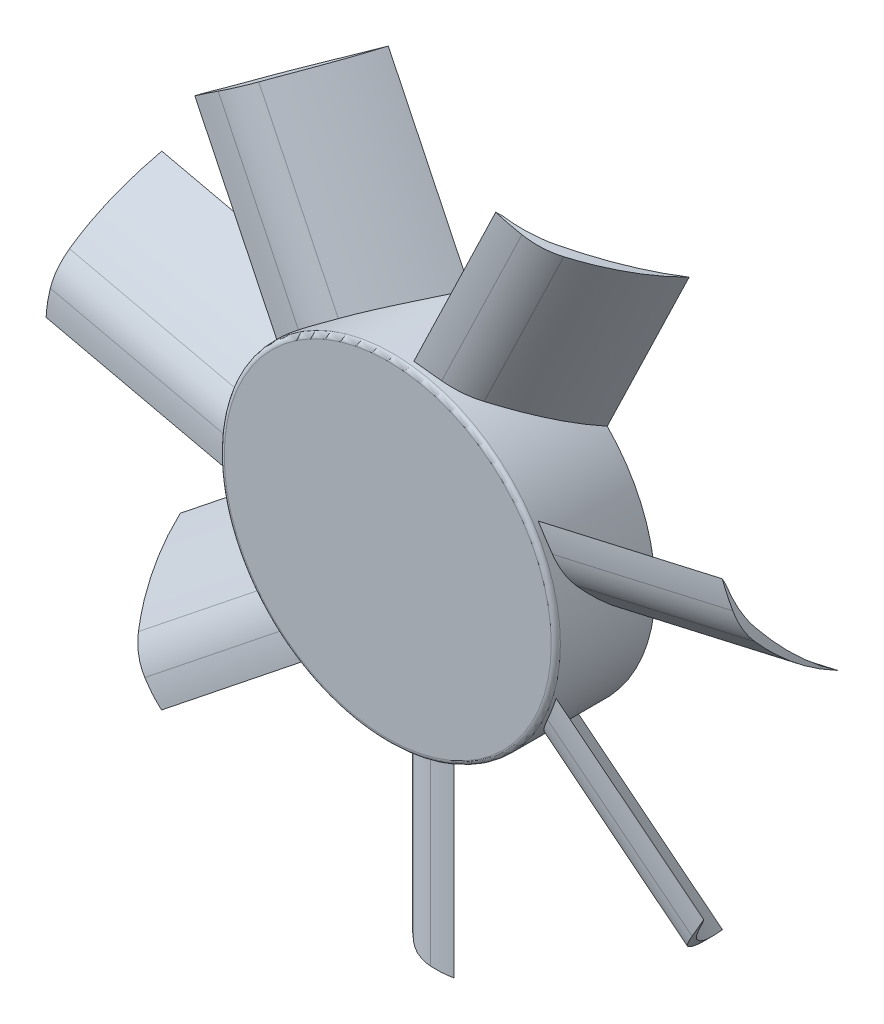
from build123d import *

# Parameters (mm, degrees)
SKETCH_1_R               = 11
EXTRUDE_1_DEPTH          = 6.5
SKETCH_2_R               = 9.75
CUT_EXTRUDE_1_DEPTH      = 5.5
SKETCH_3_R               = 0.7
EXTRUDE_2_DEPTH          = 7.5
CHAMFER_1_SIZE           = 0.6
EXTRUDE_START            = -10
EXTRUDE_3_DEPTH          = 23
PATTERN_CIRCULAR_1_COUNT = 7
FILLET_1_R               = 0.3
SKETCH_5_OUTSIDE_W       = 86.532
SKETCH_5_OUTSIDE_H       = 84.877
SKETCH_5_OUTSIDE_R       = 23
CUT_EXTRUDE_2_DEPTH      = 23


with BuildPart() as part:
    # Эскиз1 → Бобышка-Вытянуть1 (new body)
    with BuildSketch(Plane.XY):
        Circle(SKETCH_1_R)
    extrude(amount=EXTRUDE_1_DEPTH)

    # Эскиз2 → Вырез-Вытянуть1 (cut)
    with BuildSketch(Plane(origin=(0, 0, 0), x_dir=(-1, 0, 0), z_dir=(0, 0, -1))):
        Circle(SKETCH_2_R)
    extrude(amount=-CUT_EXTRUDE_1_DEPTH, mode=Mode.SUBTRACT)

    # Эскиз3 → Бобышка-Вытянуть2 (add)
    with BuildSketch(Plane(origin=(0, 0, 5.5), x_dir=(-1, 0, 0), z_dir=(0, 0, -1))):
        Circle(SKETCH_3_R)
    extrude(amount=EXTRUDE_2_DEPTH)

    # Фаска1
    chamfer_1_edges = [part.edges().sort_by_distance(p)[0] for p in [
        (0.7, 0, -2),
    ]]
    chamfer(chamfer_1_edges, length=CHAMFER_1_SIZE)

    # Эскиз4 → Бобышка-Вытянуть3 (add)
    with BuildSketch(Plane(origin=(0, 0, 0), x_dir=(1, 0, 0), z_dir=(0, 1, 0)).offset(EXTRUDE_START)):
        with BuildLine():
            ThreePointArc((3.75, -5.9), (2.910954768, -5.877455841), (2.076425924, -5.787640746))
            ThreePointArc((2.076425924, -5.787640746), (1.016898237, -5.476222818), (0.082906283, -4.886952865))
            ThreePointArc((0.082906283, -4.886952865), (-2.084101368, -2.63998988), (-3.75, 0))
            ThreePointArc((-3.75, 0), (-1.712075741, -2.552424329), (0.739315837, -4.710822941))
            ThreePointArc((0.739315837, -4.710822941), (2.002660979, -5.416468702), (3.40130611, -5.787640746))
            ThreePointArc((3.40130611, -5.787640746), (3.575082247, -5.845591808), (3.75, -5.9))
        make_face()
    extrude_3 = extrude(amount=-EXTRUDE_3_DEPTH)

    # Круговой массив1: Бобышка-Вытянуть3 ×7 about axis
    pattern_circular_1_axis = Axis((0, 0, 6.5), (0, 0, -1))
    for i in range(1, PATTERN_CIRCULAR_1_COUNT):
        add(extrude_3.rotate(pattern_circular_1_axis, i * 360 / PATTERN_CIRCULAR_1_COUNT))

    # Скругление1
    fillet_1_edges = [part.edges().sort_by_distance(p)[0] for p in [
        (-11, 0, 6.5),
    ]]
    fillet(fillet_1_edges, radius=FILLET_1_R)

    # Эскиз5 outside → Вырез-Вытянуть2 (cut)
    with BuildSketch(Plane.XY.offset(6.5)):
        with Locations((0, -0.8205)):
            Rectangle(SKETCH_5_OUTSIDE_W, SKETCH_5_OUTSIDE_H)
        Circle(SKETCH_5_OUTSIDE_R, mode=Mode.SUBTRACT)
    extrude(amount=-CUT_EXTRUDE_2_DEPTH, mode=Mode.SUBTRACT)


solid = part.part
